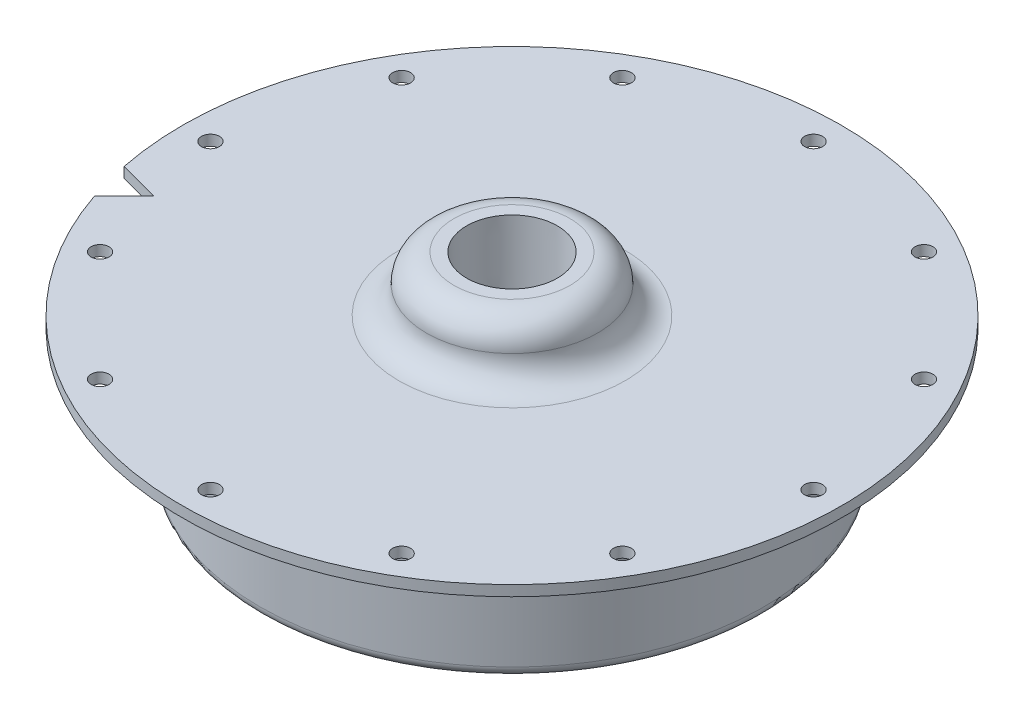
from build123d import *

# Parameters (mm, degrees)
F_36_0_1065_DIAMETER_HOLE1_D = 2.7051
CIRPATTERN1_COUNT            = 12
CUT_EXTRUDE1_DEPTH           = 1.5875


with BuildPart() as part:
    # Sketch1 → Revolve1 (revolve)
    with BuildSketch(Plane.XY):
        with BuildLine():
            Line((-49.784, 0), (-39.6875, 0))
            ThreePointArc((-39.6875, 0), (-38.564967985, -0.464967985), (-38.1, -1.5875))
            Line((-38.1, -1.5875), (-38.1, -17.4625))
            ThreePointArc((-38.1, -17.4625), (-36.5125, -19.05), (-34.925, -17.4625))
            Line((-34.925, -17.4625), (-34.925, -3.175))
            ThreePointArc((-34.925, -3.175), (-33.99506403, -0.92993597), (-31.75, 0))
            Line((-31.75, 0), (-5.588, 0))
            Line((-5.588, 0), (-5.588, 9.906))
            Line((-5.588, 9.906), (-8.763, 9.906))
            ThreePointArc((-8.763, 9.906), (-11.70403388, 8.68778388), (-12.92225, 5.74675))
            ThreePointArc((-12.92225, 5.74675), (-14.14046612, 2.80571612), (-17.0815, 1.5875))
            Line((-17.0815, 1.5875), (-49.784, 1.5875))
            Line((-49.784, 1.5875), (-49.784, 0))
        make_face()
    revolve(axis=Axis((0, 55, 0), (0, -1, 0)))

    # #36 (0.1065) Diameter Hole1 (through all)
    with Locations(Plane(origin=(0, 1.5875, 0), x_dir=(1, 0, 0), z_dir=(0, 1, 0))):
        with Locations((-45.5549, 0)):
            f_36_0_1065_diameter_hole1 = Hole(F_36_0_1065_DIAMETER_HOLE1_D / 2)

    # CirPattern1: #36 (0.1065) Diameter Hole1 ×12 about axis
    cirpattern1_axis = Axis((0, 0, 0), (0, 1, 0))
    for i in range(1, CIRPATTERN1_COUNT):
        add(f_36_0_1065_diameter_hole1.rotate(cirpattern1_axis, i * 360 / CIRPATTERN1_COUNT), mode=Mode.SUBTRACT)

    # Sketch5 → 1/4 NPT Tapped Hole1 (revolve, cut)
    with BuildSketch(Plane(origin=(0, 9.906, 0), x_dir=(0, 0, 1), z_dir=(1, 0, 0))):
        Polygon((0, 0), (0, 28.956), (5.5626, 28.956), (5.5626, 9.906), (6.557984794, 9.906), (6.8545837, 0), align=None)
    revolve(axis=Axis((0, 16.256, 0), (0, -1, 0)), mode=Mode.SUBTRACT)

    # Sketch6 → Cut-Extrude1 (cut)
    with BuildSketch(Plane(origin=(0, 1.5875, 0), x_dir=(1, 0, 0), z_dir=(0, 1, 0))):
        with BuildLine():
            Line((-47.168007396, -15.925631363), (-42.677879335, -11.435503303))
            Line((-42.677879335, -11.435503303), (-48.811508332, -9.792002366))
            ThreePointArc((-48.811508332, -9.792002366), (-48.087651336, -12.885047341), (-47.168007396, -15.925631363))
        make_face()
    extrude(amount=-CUT_EXTRUDE1_DEPTH, mode=Mode.SUBTRACT)


solid = part.part
